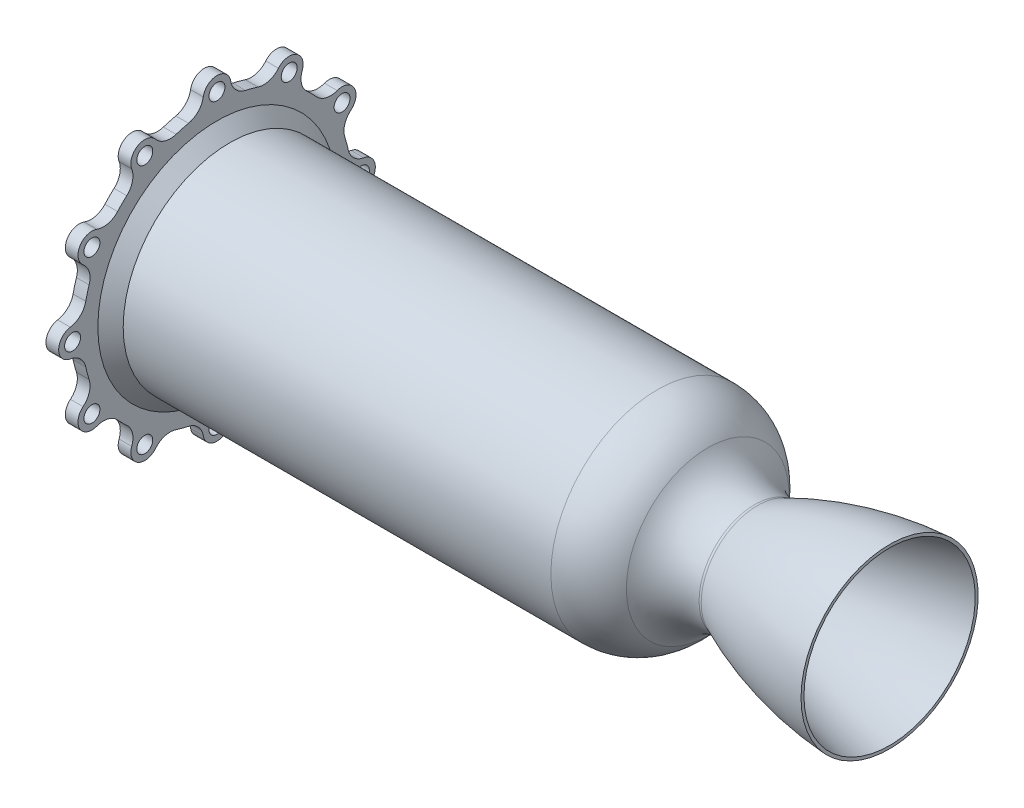
from build123d import *

# Parameters (mm, degrees)
CHAMFER1_SIZE      = 6.35
FILLET1_R          = 1.27
HOLE2_D            = 8
HOLE2_DEPTH        = 6.351
CIRPATTERN3_COUNT  = 12
CUT_EXTRUDE1_DEPTH = 6.35
CIRPATTERN4_COUNT  = 12


with BuildPart() as part:
    # Sketch1 → Revolve1 (revolve)
    with BuildSketch(Plane.XY):
        with BuildLine():
            Line((67.605732053, 44.399981539), (67.605732053, 42.924896029))
            add(Edge.make_bspline(
                [(3.699332053, 22.287076755), (3.920712382, 22.390304603), (4.345976214, 22.587493688), (5.426964621, 23.086580245), (6.285284861, 23.473631857), (7.738021552, 24.126454308), (8.992112304, 24.675947976), (10.384710428, 25.279484402), (11.70170182, 25.837381302), (12.793338352, 26.295269866), (14.135940428, 26.849765516), (15.764867402, 27.511372995), (17.662770861, 28.264713625), (19.844674272, 29.108343585), (22.031204137, 29.931269352), (24.226431999, 30.735853811), (26.427505676, 31.521219446), (28.635619952, 32.288372028), (31.288672745, 33.185713053), (34.506348054, 34.237672022), (37.736879791, 35.249222432), (40.979366995, 36.221743138), (43.786032375, 37.033687046), (46.035838807, 37.667041581), (48.290382755, 38.284554294), (50.548556834, 38.886309744), (52.811800297, 39.472911817), (55.07711252, 40.044024319), (57.06541171, 40.531369751), (58.767174947, 40.938968781), (60.19427876, 41.274230025), (61.322948972, 41.535921755), (62.48152855, 41.800252837), (63.586271633, 42.049457669), (64.79289936, 42.316666922), (65.80370836, 42.538638984), (66.875545368, 42.769110626), (67.366804545, 42.874113683), (67.605732053, 42.924896029)],
                knots=[0.082932585, 0.082932585, 0.082932585, 0.082932585, 0.082932585, 0.097450672, 0.111968759, 0.126486844, 0.141004929, 0.170041082, 0.184559169, 0.199077256, 0.213595339, 0.228113422, 0.257149585, 0.28618575, 0.315221915, 0.344258077, 0.373294238, 0.402330408, 0.431366568, 0.460402735, 0.51246758, 0.570539907, 0.599576074, 0.62861224, 0.657648405, 0.68668457, 0.715720735, 0.7447569, 0.773793065, 0.802829229, 0.817347312, 0.831865394, 0.846383476, 0.860901558, 0.87541964, 0.889937721, 0.904455803, 0.918973885, 0.918973885, 0.918973885, 0.918973885, 0.918973885], degree=4))
            ThreePointArc((3.699332053, 22.287076755), (1.885501224, 21.740048091), (0, 21.555365189))
            ThreePointArc((0, 21.555365189), (-16.471530776, 25.76531333), (-28.902915867, 37.362539472))
            ThreePointArc((-28.902915867, 37.362539472), (-38.997243823, 46.779527458), (-52.372184136, 50.19802))
            Line((-52.372184136, 50.19802), (-275.892184136, 50.19802))
            Line((-275.892184136, 50.19802), (-275.892184136, 53.37302))
            Line((-275.892184136, 53.37302), (-272.717184136, 53.37302))
            Line((-272.717184136, 53.37302), (-272.717184136, 59.72302))
            Line((-272.717184136, 59.72302), (-275.892184136, 59.72302))
            Line((-275.892184136, 59.72302), (-275.892184136, 62.89802))
            Line((-275.892184136, 62.89802), (-273.352184136, 62.89802))
            Line((-273.352184136, 62.89802), (-273.352184136, 65.43802))
            Line((-273.352184136, 65.43802), (-275.892184136, 65.43802))
            Line((-275.892184136, 65.43802), (-275.892184136, 79.375))
            Line((-275.892184136, 79.375), (-269.542184136, 79.375))
            Line((-269.542184136, 79.375), (-269.542184136, 53.37302))
            Line((-269.542184136, 53.37302), (-48.81204017, 53.37302))
            ThreePointArc((-48.81204017, 53.37302), (-34.703370767, 50.052634609), (-23.556389587, 40.788492877))
            ThreePointArc((-23.556389587, 40.788492877), (-13.424590025, 31.336547669), (0, 27.905365189))
            ThreePointArc((0, 27.905365189), (0.702771779, 27.979518545), (1.374590841, 28.19871262))
            ThreePointArc((1.374590841, 28.19871262), (33.756678416, 39.297841731), (67.605732053, 44.399981539))
        make_face()
    revolve(axis=Axis((-236.474550185, 0, 0), (1, 0, 0)))

    # Chamfer1
    chamfer1_edges = [part.edges().sort_by_distance(p)[0] for p in [
        (-269.542184136, -53.37302, 0),
    ]]
    chamfer(chamfer1_edges, length=CHAMFER1_SIZE)

    # Fillet1
    fillet1_edges = [part.edges().sort_by_distance(p)[0] for p in [
        (-272.717184136, -59.72302, 0),
        (-272.717184136, -53.37302, 0),
        (-275.892184136, -53.37302, 0),
        (-275.892184136, -50.19802, 0),
    ]]
    fillet(fillet1_edges, radius=FILLET1_R)

    # Hole2
    with Locations(Plane.ZY.offset(275.892184136)):
        with Locations((0, 72.39)):
            hole2 = Hole(HOLE2_D / 2, depth=HOLE2_DEPTH)

    # CirPattern3: Hole2 ×12 about axis
    cirpattern3_axis = Axis((0, 0, 0), (1, 0, 0))
    for i in range(1, CIRPATTERN3_COUNT):
        add(hole2.rotate(cirpattern3_axis, i * 360 / CIRPATTERN3_COUNT), mode=Mode.SUBTRACT)

    # Sketch11 → Cut-Extrude1 (cut)
    with BuildSketch(Plane.ZY.offset(275.892184136)):
        with BuildLine():
            ThreePointArc((79.375, 0), (77.717548697, 4.517460557), (73.531778846, 6.891049707))
            ThreePointArc((73.531778846, 6.891049707), (68.521982999, 9.388428721), (65.780227273, 14.268770092))
            ThreePointArc((65.780227273, 14.268770092), (65.016467368, 17.421109926), (64.101732931, 20.532996256))
            ThreePointArc((64.101732931, 20.532996256), (64.035992356, 26.130373726), (67.12591332, 30.798065318))
            ThreePointArc((67.12591332, 30.798065318), (69.56410177, 34.946538746), (68.740766425, 39.6875))
            ThreePointArc((68.740766425, 39.6875), (76.670362462, 20.543761705), (79.375, 0))
        make_face()
    cut_extrude1 = extrude(amount=-CUT_EXTRUDE1_DEPTH, mode=Mode.SUBTRACT)

    # CirPattern4: Cut-Extrude1 ×12 about axis
    cirpattern4_axis = Axis((0, 0, 0), (1, 0, 0))
    for i in range(1, CIRPATTERN4_COUNT):
        add(cut_extrude1.rotate(cirpattern4_axis, i * 360 / CIRPATTERN4_COUNT), mode=Mode.SUBTRACT)


solid = part.part
